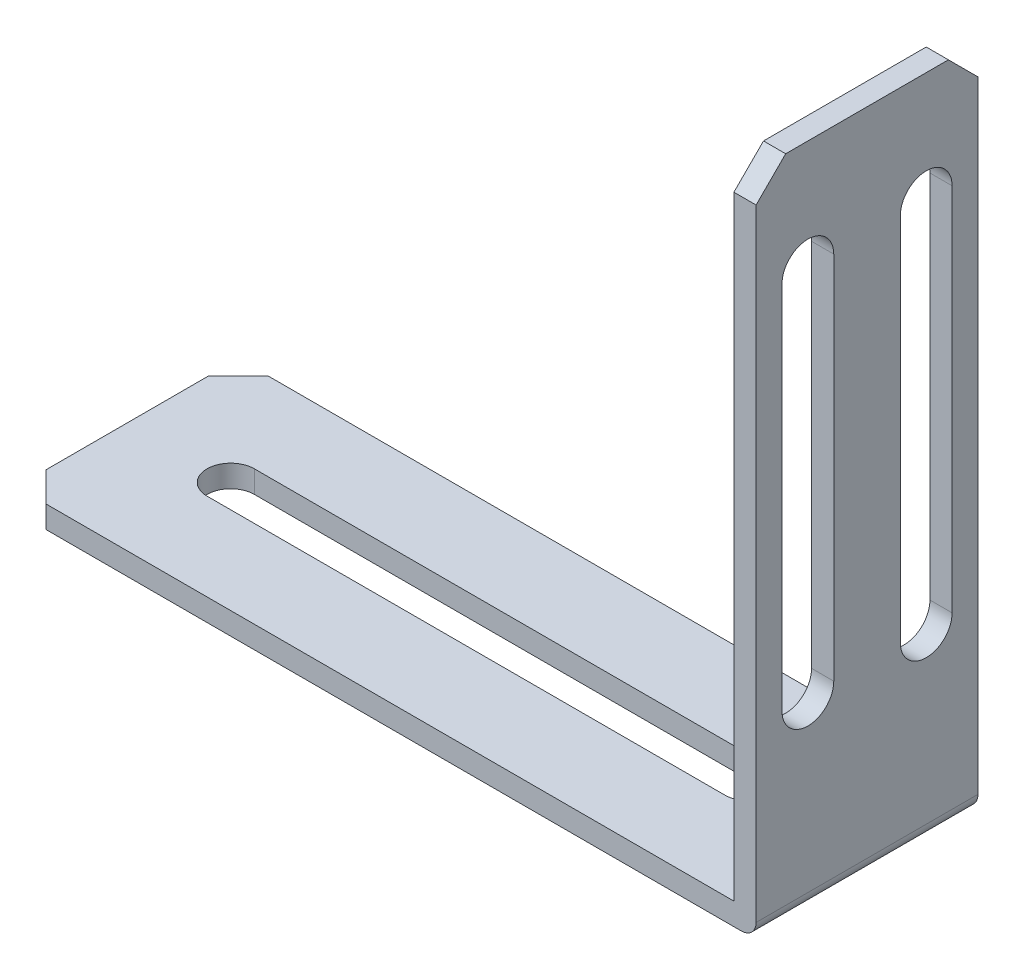
from build123d import *

# Parameters (mm, degrees)
BOSS_EXTRUDE1_DEPTH = 15
CUT_EXTRUDE1_DEPTH  = 2.5
CUT_EXTRUDE2_DEPTH  = 2.5
CHAMFER1_SIZE       = 2
FILLET1_R           = 1


with BuildPart() as part:
    # Sketch1 → Boss-Extrude1 (new body)
    with BuildSketch(Plane.XY):
        Polygon((-218.84057971, 0), (-170.34057971, 0), (-170.34057971, 43.5), (-168.84057971, 43.5), (-168.84057971, -1.5), (-218.84057971, -1.5), align=None)
    extrude(amount=BOSS_EXTRUDE1_DEPTH)

    # Sketch2 → Cut-Extrude1 (cut, through all)
    with BuildSketch(Plane(origin=(0, 0, 0), x_dir=(1, 0, 0), z_dir=(0, 1, 0))):
        with BuildLine():
            Line((-176.854809789, -9.1), (-211.854809789, -9.1))
            ThreePointArc((-211.854809789, -9.1), (-213.454809789, -7.5), (-211.854809789, -5.9))
            Line((-211.854809789, -5.9), (-176.854809789, -5.9))
            ThreePointArc((-176.854809789, -5.9), (-175.254809789, -7.5), (-176.854809789, -9.1))
        make_face()
    extrude(amount=-CUT_EXTRUDE1_DEPTH, mode=Mode.SUBTRACT)

    # Sketch3 → Cut-Extrude2 (cut, through all)
    with BuildSketch(Plane.ZY.offset(170.34057971)):
        with BuildLine():
            Line((1.75, 36), (1.75, 11))
            ThreePointArc((1.75, 11), (3.5, 9.25), (5.25, 11))
            Line((5.25, 11), (5.25, 36))
            ThreePointArc((5.25, 36), (3.5, 37.75), (1.75, 36))
        make_face()
        with BuildLine():
            Line((9.75, 36), (9.75, 11))
            ThreePointArc((9.75, 11), (11.5, 9.25), (13.25, 11))
            Line((13.25, 11), (13.25, 36))
            ThreePointArc((13.25, 36), (11.5, 37.75), (9.75, 36))
        make_face()
    extrude(amount=-CUT_EXTRUDE2_DEPTH, mode=Mode.SUBTRACT)

    # Chamfer1
    chamfer1_edges = [part.edges().sort_by_distance(p)[0] for p in [
        (-169.59057971, 43.5, 15),
        (-218.84057971, -0.75, 15),
        (-169.59057971, 43.5, 0),
        (-218.84057971, -0.75, 0),
    ]]
    chamfer(chamfer1_edges, length=CHAMFER1_SIZE)

    # Fillet1
    fillet1_edges = [part.edges().sort_by_distance(p)[0] for p in [
        (-168.84057971, -1.5, 7.5),
    ]]
    fillet(fillet1_edges, radius=FILLET1_R)


solid = part.part
